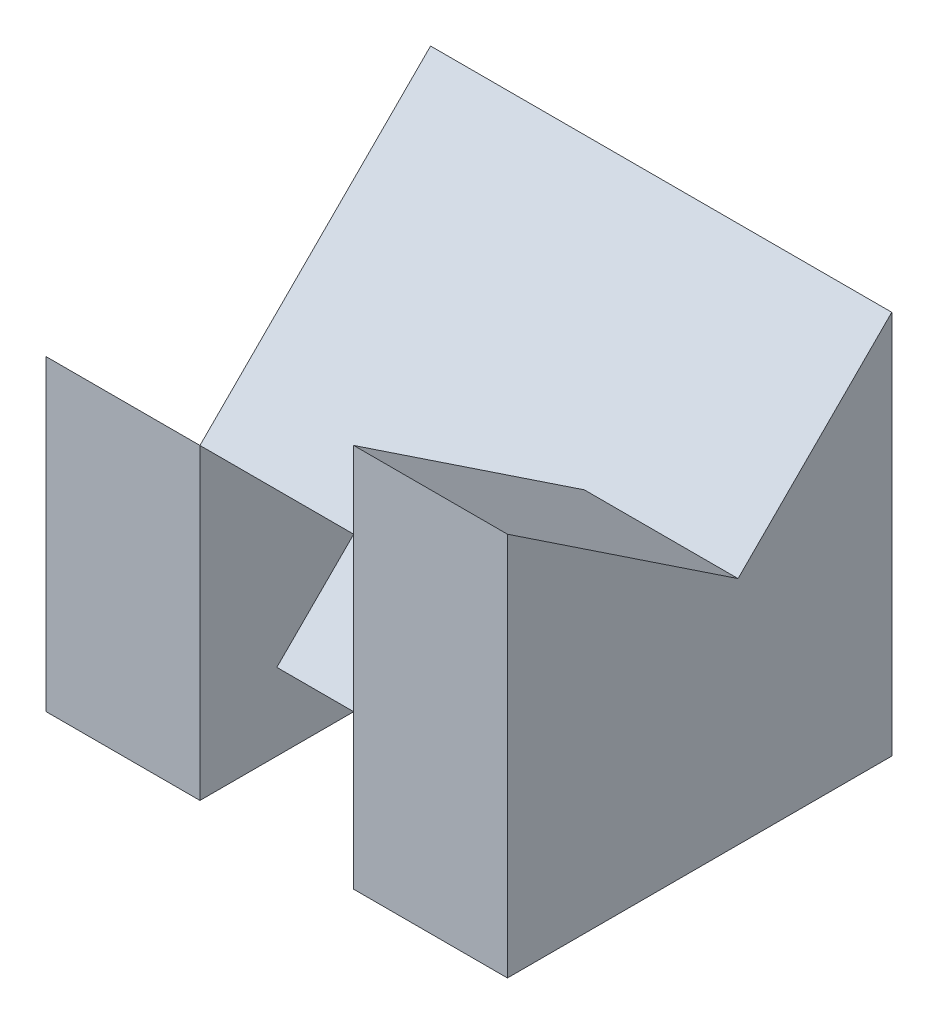
from build123d import *

# Parameters (mm, degrees)
BOSS_EXTRUDE2_DEPTH = 5
SKETCH23_W          = 2
SKETCH23_H          = 1
CUT_EXTRUDE16_DEPTH = 5
CUT_EXTRUDE17_DEPTH = 7
SKETCH25_W          = 2
SKETCH25_H          = 2
SKETCH25_H_2        = 3
BOSS_EXTRUDE5_DEPTH = 5
CUT_EXTRUDE18_DEPTH = 2
CUT_EXTRUDE19_DEPTH = 2


with BuildPart() as part:
    # Sketch7 → Boss-Extrude2 (new body)
    with BuildSketch(Plane.XY):
        Polygon((0, 0), (0, 5), (6, 5), (6, 0), (4, 0), (4, 1), (2, 1), (2, 0), align=None)
    extrude(amount=BOSS_EXTRUDE2_DEPTH)

    # Sketch23 → Cut-Extrude16 (cut)
    with BuildSketch(Plane(origin=(0, 5, 0), x_dir=(1, 0, 0), z_dir=(0, 1, 0))):
        with Locations((3, -4.5)):
            Rectangle(SKETCH23_W, SKETCH23_H)
    extrude(amount=-CUT_EXTRUDE16_DEPTH, mode=Mode.SUBTRACT)

    # Sketch24 → Cut-Extrude17 (cut)
    with BuildSketch(Plane.ZY):
        Polygon((0, 5), (4, 1), (4, 5), align=None)
    extrude(amount=-CUT_EXTRUDE17_DEPTH, mode=Mode.SUBTRACT)

    # Sketch25 → Boss-Extrude5 (add)
    with BuildSketch(Plane.XZ):
        with Locations((1, 4)):
            Rectangle(SKETCH25_W, SKETCH25_H)
        with Locations((5, 3.5)):
            Rectangle(SKETCH25_W, SKETCH25_H_2)
    extrude(amount=-BOSS_EXTRUDE5_DEPTH)

    # Sketch26 → Cut-Extrude18 (cut)
    with BuildSketch(Plane.ZY):
        Polygon((5, 5), (5, 4), (3, 2), (3, 5), align=None)
    extrude(amount=-CUT_EXTRUDE18_DEPTH, mode=Mode.SUBTRACT)

    # Sketch27 → Cut-Extrude19 (cut)
    with BuildSketch(Plane(origin=(6, 0, 0), x_dir=(0, 0, -1), z_dir=(1, 0, 0))):
        Polygon((-5, 5), (-2, 3), (-2, 5), align=None)
    extrude(amount=-CUT_EXTRUDE19_DEPTH, mode=Mode.SUBTRACT)


solid = part.part
